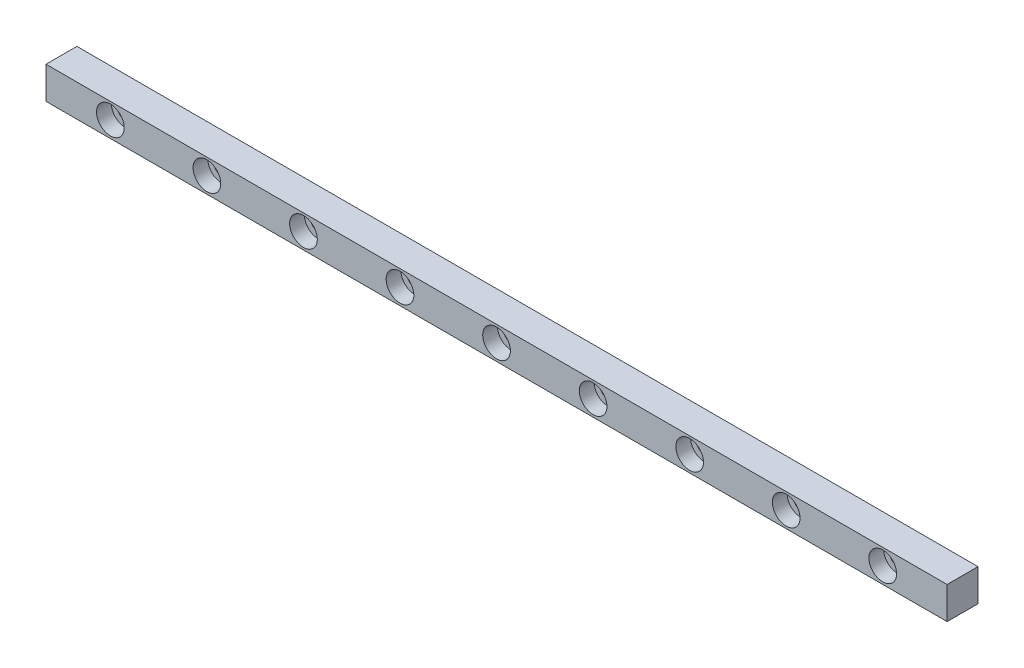
from build123d import *

# Parameters (mm, degrees)
SKETCH_1_W                = 140
SKETCH_1_H                = 5
EXTRUDE_1_DEPTH           = 4.8
HOLE_WIZARD_1_D           = 2.4
HOLE_WIZARD_1_DEPTH       = 5.2
HOLE_WIZARD_1_CBORE_D     = 4.3
HOLE_WIZARD_1_CBORE_DEPTH = 2.3
HOLE_WIZARD_1_TIP         = 0.721032743


with BuildPart() as part:
    # 草图1 → 凸台-拉伸1 (new body)
    with BuildSketch(Plane.XY):
        Rectangle(SKETCH_1_W, SKETCH_1_H)
    extrude(amount=EXTRUDE_1_DEPTH)

    # 打孔尺寸(%根据)内六角圆柱头螺钉的类型1
    with Locations(Plane.XY.offset(4.8)):
        with Locations((-60, 0), (-45, 0), (-30, 0), (-15, 0), (0, 0), (15, 0), (30, 0), (45, 0), (60, 0)):
            CounterBoreHole(HOLE_WIZARD_1_D / 2, HOLE_WIZARD_1_CBORE_D / 2, HOLE_WIZARD_1_CBORE_DEPTH, depth=HOLE_WIZARD_1_DEPTH)
            with Locations((0, 0, -(HOLE_WIZARD_1_DEPTH + HOLE_WIZARD_1_TIP / 2))):  # 118° drill point
                Cone(0, HOLE_WIZARD_1_D / 2, HOLE_WIZARD_1_TIP, mode=Mode.SUBTRACT)


solid = part.part
